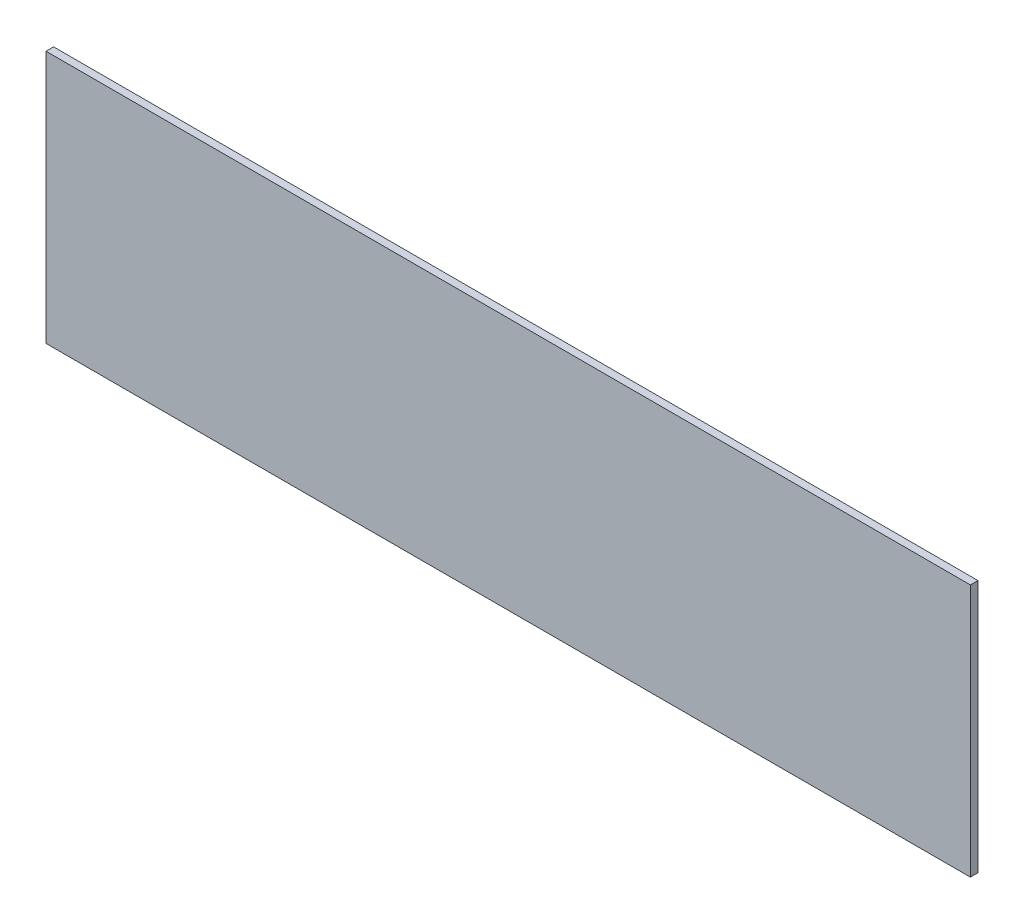
from build123d import *

# Parameters (mm, degrees)
SKETCH1_W           = 387.35
SKETCH1_H           = 106.045
BOSS_EXTRUDE1_DEPTH = 3.175


with BuildPart() as part:
    # Sketch1 → Boss-Extrude1 (new body)
    with BuildSketch(Plane.XY):
        Rectangle(SKETCH1_W, SKETCH1_H)
    extrude(amount=BOSS_EXTRUDE1_DEPTH)


solid = part.part
